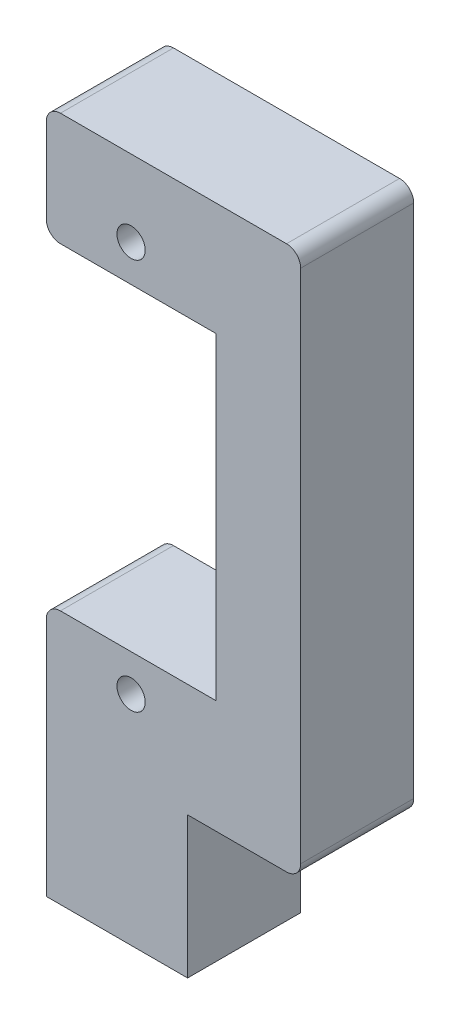
from build123d import *

# Parameters (mm, degrees)
SKETCH1_R           = 1
BOSS_EXTRUDE1_DEPTH = 8
FILLET1_R           = 1


with BuildPart() as part:
    # Sketch1 → Boss-Extrude1 (new body)
    with BuildSketch(Plane.XY):
        Polygon((0, 0), (0, 10), (8, 10), (8, 48.5), (-10, 48.5), (-10, 40.5), (2, 40.5), (2, 18), (-10, 18), (-10, 10), (-10, 0), align=None)
        with Locations((-4, 43.1)):
            Circle(SKETCH1_R, mode=Mode.SUBTRACT)
        with Locations((-4, 15.4)):
            Circle(SKETCH1_R, mode=Mode.SUBTRACT)
    extrude(amount=BOSS_EXTRUDE1_DEPTH)

    # Fillet1
    fillet1_edges = [part.edges().sort_by_distance(p)[0] for p in [
        (-10, 18, 4),
        (-10, 40.5, 4),
        (-10, 48.5, 4),
        (8, 48.5, 4),
        (8, 10, 4),
    ]]
    fillet(fillet1_edges, radius=FILLET1_R)


solid = part.part
